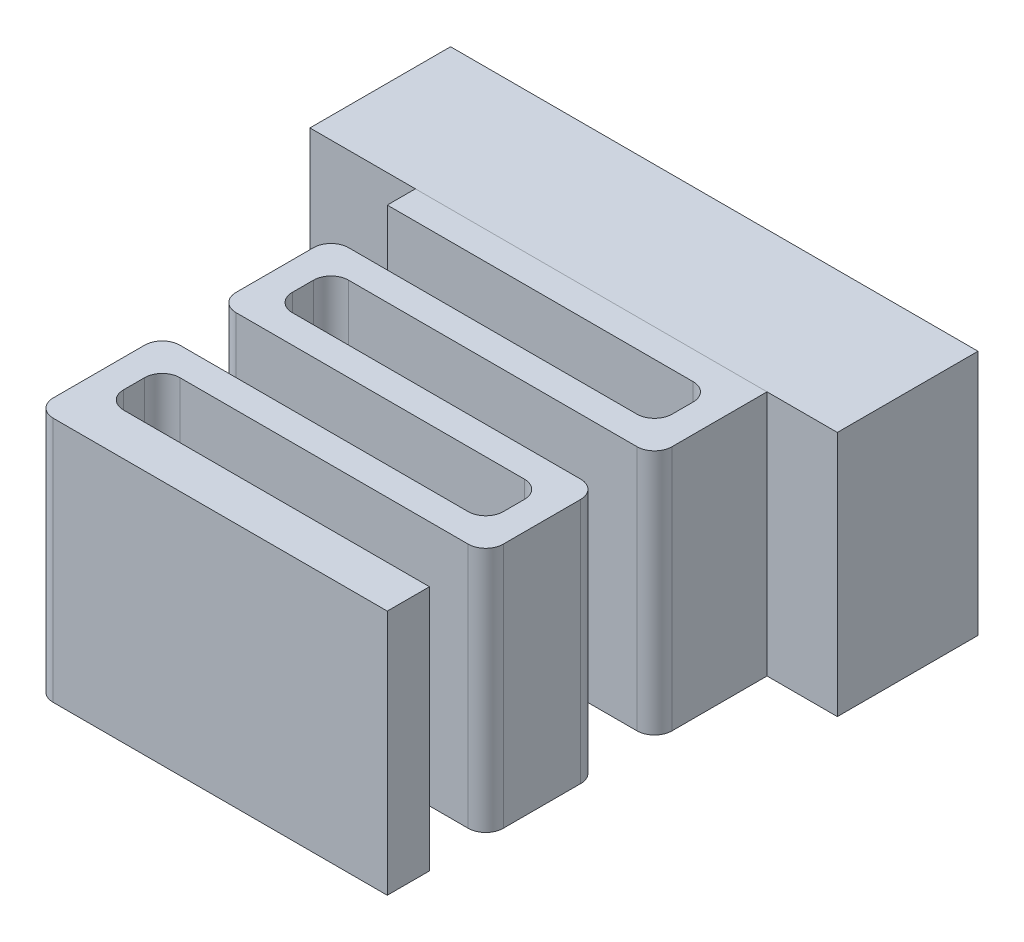
from build123d import *

# Parameters (mm, degrees)
SKETCH_1_W      = 15
SKETCH_1_H      = 7
EXTRUDE_1_DEPTH = 4
EXTRUDE_2_DEPTH = 7
FILLET_1_R      = 0.5


with BuildPart() as part:
    # 스케치1 → 보스-돌출1 (new body)
    with BuildSketch(Plane.XY):
        with Locations((-40.5, 0)):
            Rectangle(SKETCH_1_W, SKETCH_1_H)
    extrude(amount=EXTRUDE_1_DEPTH)


with BuildPart() as body_2:
    # 스케치2 → 보스-돌출2 (new body)
    with BuildSketch(Plane(origin=(0, 3.5, 0), x_dir=(1, 0, 0), z_dir=(0, 1, 0))):
        Polygon((-35, -4), (-45, -4), (-45, -4.8), (-35.8, -4.8), (-35.8, -6.4), (-45, -6.4), (-45, -9.6), (-35.8, -9.6), (-35.8, -11.2), (-45, -11.2), (-45, -12), (-45, -14.8), (-35, -14.8), (-35, -13.6), (-44.2, -13.6), (-44.2, -12), (-35, -12), (-35, -9.6), (-35, -8.8), (-44.2, -8.8), (-44.2, -7.2), (-35, -7.2), align=None)
    extrude(amount=-EXTRUDE_2_DEPTH)

    # 필렛1
    fillet_1_edges = [body_2.edges().sort_by_distance(p)[0] for p in [
        (-35, 0, 7.2),
        (-44.2, 0, 7.2),
        (-44.2, 0, 8.8),
        (-35, 0, 8.8),
        (-35, 0, 12),
        (-44.2, 0, 12),
        (-44.2, 0, 13.6),
        (-45, 0, 14.8),
        (-45, 0, 11.2),
        (-35.8, 0, 11.2),
        (-35.8, 0, 9.6),
        (-45, 0, 9.6),
        (-45, 0, 6.4),
        (-35.8, 0, 6.4),
        (-35.8, 0, 4.8),
    ]]
    fillet(fillet_1_edges, radius=FILLET_1_R)


solid = Compound([part.part, body_2.part])
